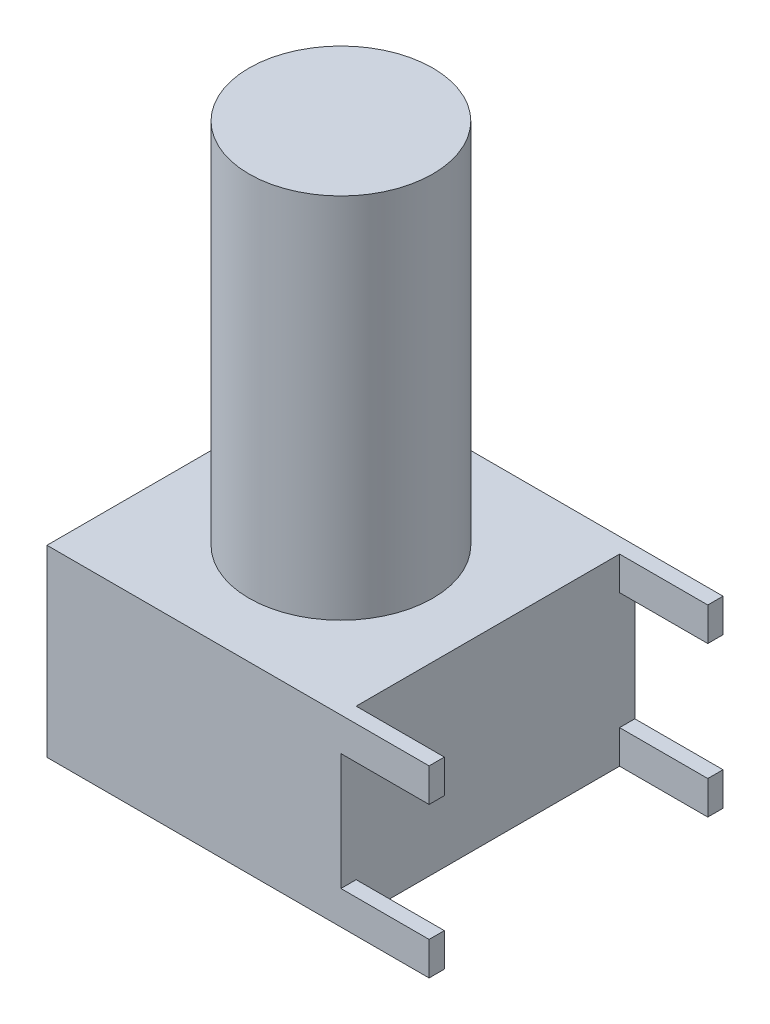
from build123d import *

# Parameters (mm, degrees)
SKETCH1_R           = 3.175
BOSS_EXTRUDE1_DEPTH = 12.7
SKETCH1_3_W         = 10.16
SKETCH1_3_H         = 10.16
BOSS_EXTRUDE2_DEPTH = 6.35
SKETCH2_W           = 0.527405638
SKETCH2_H           = 1.155182197
BOSS_EXTRUDE3_DEPTH = 3.048


with BuildPart() as part:
    # Sketch1 → Boss-Extrude1 (new body)
    with BuildSketch(Plane(origin=(0, 0, 0), x_dir=(1, 0, 0), z_dir=(0, 1, 0))):
        Circle(SKETCH1_R)
    extrude(amount=BOSS_EXTRUDE1_DEPTH)

    # Sketch1_3 → Boss-Extrude2 (add)
    with BuildSketch(Plane(origin=(0, 0, 0), x_dir=(1, 0, 0), z_dir=(0, 1, 0))):
        Rectangle(SKETCH1_3_W, SKETCH1_3_H)
    extrude(amount=-BOSS_EXTRUDE2_DEPTH)

    # Sketch2 → Boss-Extrude3 (add)
    with BuildSketch(Plane(origin=(5.08, 0, 0), x_dir=(0, 0, -1), z_dir=(1, 0, 0))):
        with Locations((-4.816297181, -5.772408902)):
            Rectangle(SKETCH2_W, SKETCH2_H)
        with Locations((4.816297181, -5.772408902)):
            Rectangle(SKETCH2_W, SKETCH2_H)
        with Locations((-4.816297181, -0.577591099)):
            Rectangle(SKETCH2_W, SKETCH2_H)
        with Locations((4.816297181, -0.577591099)):
            Rectangle(SKETCH2_W, SKETCH2_H)
    extrude(amount=BOSS_EXTRUDE3_DEPTH)


solid = part.part
